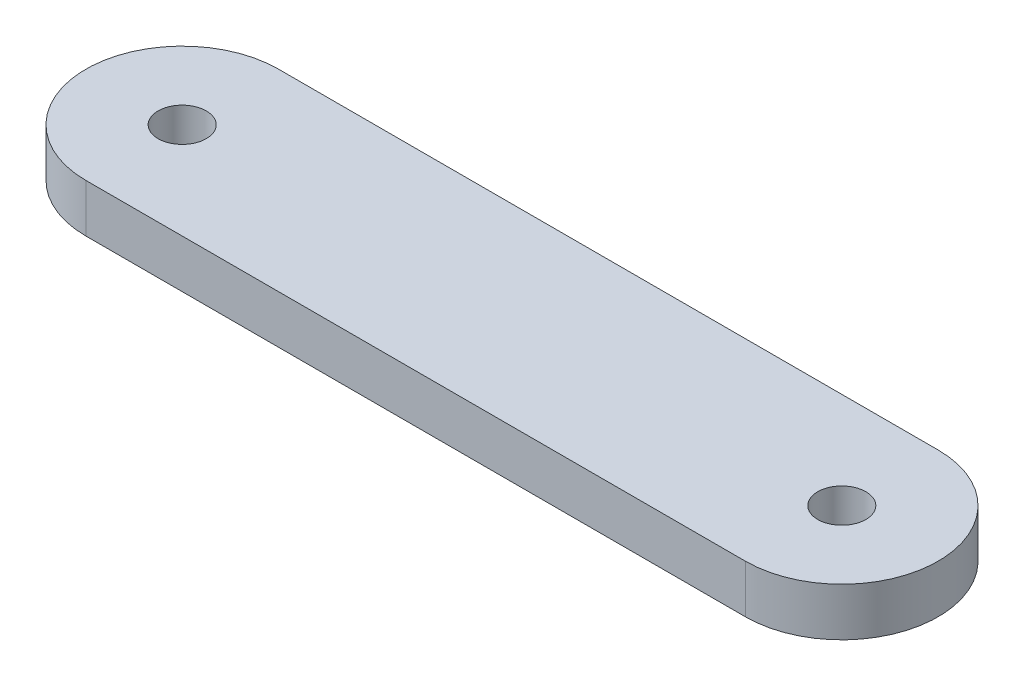
from build123d import *

# Parameters (mm, degrees)
SKETCH1_R           = 1.5875
BOSS_EXTRUDE1_DEPTH = 3.175


with BuildPart() as part:
    # Sketch1 → Boss-Extrude1 (new body)
    with BuildSketch(Plane(origin=(0, 0, 0), x_dir=(1, 0, 0), z_dir=(0, 1, 0))):
        with BuildLine():
            Line((0, 6.35), (43.472608, 6.35))
            ThreePointArc((43.472608, 6.35), (49.822608, 0), (43.472608, -6.35))
            Line((43.472608, -6.35), (0, -6.35))
            ThreePointArc((0, -6.35), (-6.35, 0), (0, 6.35))
        make_face()
        Circle(SKETCH1_R, mode=Mode.SUBTRACT)
        with Locations((43.472608, 0)):
            Circle(SKETCH1_R, mode=Mode.SUBTRACT)
    extrude(amount=BOSS_EXTRUDE1_DEPTH)


solid = part.part
